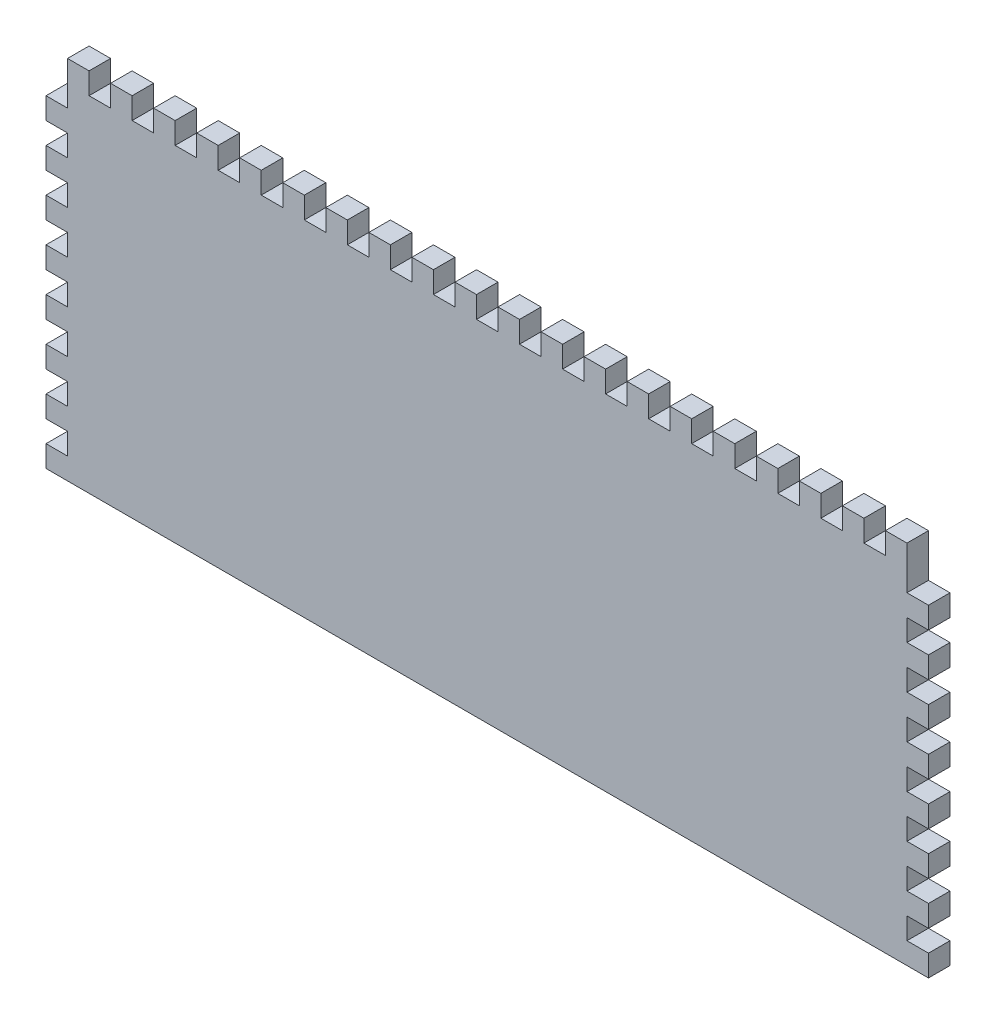
from build123d import *

# Parameters (mm, degrees)
SKETCH1_W               = 260.35
SKETCH1_H               = 107.95
BOSS_EXTRUDE1_DEPTH     = 6.35
SKETCH3_W               = 6.35
SKETCH3_H               = 6.35
CUT_EXTRUDE1_DEPTH      = 7.35
LPATTERN1_COUNT         = 8
LPATTERN1_PITCH         = 12.7
MIRROR1_COPY_1_SKETCH_W = 6.35
MIRROR1_COPY_1_SKETCH_H = 6.35
MIRROR1_COPY_1_DEPTH    = 7.35
MIRROR1_COPY_2_SKETCH_W = 6.35
MIRROR1_COPY_2_SKETCH_H = 6.35
MIRROR1_COPY_2_DEPTH    = 7.35
MIRROR1_COPY_3_SKETCH_W = 6.35
MIRROR1_COPY_3_SKETCH_H = 6.35
MIRROR1_COPY_3_DEPTH    = 7.35
MIRROR1_COPY_4_SKETCH_W = 6.35
MIRROR1_COPY_4_SKETCH_H = 6.35
MIRROR1_COPY_4_DEPTH    = 7.35
MIRROR1_COPY_5_SKETCH_W = 6.35
MIRROR1_COPY_5_SKETCH_H = 6.35
MIRROR1_COPY_5_DEPTH    = 7.35
MIRROR1_COPY_6_SKETCH_W = 6.35
MIRROR1_COPY_6_SKETCH_H = 6.35
MIRROR1_COPY_6_DEPTH    = 7.35
MIRROR1_COPY_7_SKETCH_W = 6.35
MIRROR1_COPY_7_SKETCH_H = 6.35
MIRROR1_COPY_7_DEPTH    = 7.35
SKETCH4_W               = 6.35
SKETCH4_H               = 6.35
CUT_EXTRUDE2_DEPTH      = 6.35
LPATTERN2_COUNT         = 21
LPATTERN2_PITCH         = 12.7


with BuildPart() as part:
    # Sketch1 → Boss-Extrude1 (new body)
    with BuildSketch(Plane.XY):
        Rectangle(SKETCH1_W, SKETCH1_H)
    extrude(amount=BOSS_EXTRUDE1_DEPTH)

    # Sketch3 → Cut-Extrude1 (cut, through all)
    with BuildSketch(Plane.XY.offset(6.35)):
        with Locations((127, -44.45)):
            Rectangle(SKETCH3_W, SKETCH3_H)
    cut_extrude1 = extrude(amount=-CUT_EXTRUDE1_DEPTH, mode=Mode.SUBTRACT)

    # LPattern1: Cut-Extrude1 ×8
    with Locations(*[(0, i * LPATTERN1_PITCH, 0) for i in range(1, LPATTERN1_COUNT)]):
        add(cut_extrude1, mode=Mode.SUBTRACT)

    # Mirror1: Cut-Extrude1 across plane
    add(cut_extrude1.mirror(Plane(origin=(0, 0, 0), x_dir=(0, 0, 1), z_dir=(1, 0, 0))), mode=Mode.SUBTRACT)

    # Mirror1 copy 1 sketch → Mirror1 copy 1 (cut, through all)
    with BuildSketch(Plane(origin=(0, 12.7, 6.35), x_dir=(-1, 0, 0), z_dir=(0, 0, 1))):
        with Locations((127, 44.45)):
            Rectangle(MIRROR1_COPY_1_SKETCH_W, MIRROR1_COPY_1_SKETCH_H)
    extrude(amount=-MIRROR1_COPY_1_DEPTH, mode=Mode.SUBTRACT)

    # Mirror1 copy 2 sketch → Mirror1 copy 2 (cut, through all)
    with BuildSketch(Plane(origin=(0, 25.4, 6.35), x_dir=(-1, 0, 0), z_dir=(0, 0, 1))):
        with Locations((127, 44.45)):
            Rectangle(MIRROR1_COPY_2_SKETCH_W, MIRROR1_COPY_2_SKETCH_H)
    extrude(amount=-MIRROR1_COPY_2_DEPTH, mode=Mode.SUBTRACT)

    # Mirror1 copy 3 sketch → Mirror1 copy 3 (cut, through all)
    with BuildSketch(Plane(origin=(0, 38.1, 6.35), x_dir=(-1, 0, 0), z_dir=(0, 0, 1))):
        with Locations((127, 44.45)):
            Rectangle(MIRROR1_COPY_3_SKETCH_W, MIRROR1_COPY_3_SKETCH_H)
    extrude(amount=-MIRROR1_COPY_3_DEPTH, mode=Mode.SUBTRACT)

    # Mirror1 copy 4 sketch → Mirror1 copy 4 (cut, through all)
    with BuildSketch(Plane(origin=(0, 50.8, 6.35), x_dir=(-1, 0, 0), z_dir=(0, 0, 1))):
        with Locations((127, 44.45)):
            Rectangle(MIRROR1_COPY_4_SKETCH_W, MIRROR1_COPY_4_SKETCH_H)
    extrude(amount=-MIRROR1_COPY_4_DEPTH, mode=Mode.SUBTRACT)

    # Mirror1 copy 5 sketch → Mirror1 copy 5 (cut, through all)
    with BuildSketch(Plane(origin=(0, 63.5, 6.35), x_dir=(-1, 0, 0), z_dir=(0, 0, 1))):
        with Locations((127, 44.45)):
            Rectangle(MIRROR1_COPY_5_SKETCH_W, MIRROR1_COPY_5_SKETCH_H)
    extrude(amount=-MIRROR1_COPY_5_DEPTH, mode=Mode.SUBTRACT)

    # Mirror1 copy 6 sketch → Mirror1 copy 6 (cut, through all)
    with BuildSketch(Plane(origin=(0, 76.2, 6.35), x_dir=(-1, 0, 0), z_dir=(0, 0, 1))):
        with Locations((127, 44.45)):
            Rectangle(MIRROR1_COPY_6_SKETCH_W, MIRROR1_COPY_6_SKETCH_H)
    extrude(amount=-MIRROR1_COPY_6_DEPTH, mode=Mode.SUBTRACT)

    # Mirror1 copy 7 sketch → Mirror1 copy 7 (cut, through all)
    with BuildSketch(Plane(origin=(0, 88.9, 6.35), x_dir=(-1, 0, 0), z_dir=(0, 0, 1))):
        with Locations((127, 44.45)):
            Rectangle(MIRROR1_COPY_7_SKETCH_W, MIRROR1_COPY_7_SKETCH_H)
    extrude(amount=-MIRROR1_COPY_7_DEPTH, mode=Mode.SUBTRACT)

    # Sketch4 → Cut-Extrude2 (cut)
    with BuildSketch(Plane.XY.offset(6.35)):
        with Locations((-127, 50.8)):
            Rectangle(SKETCH4_W, SKETCH4_H)
    cut_extrude2 = extrude(amount=-CUT_EXTRUDE2_DEPTH, mode=Mode.SUBTRACT)

    # LPattern2: Cut-Extrude2 ×21
    with Locations(*[(i * LPATTERN2_PITCH, 0, 0) for i in range(1, LPATTERN2_COUNT)]):
        add(cut_extrude2, mode=Mode.SUBTRACT)


solid = part.part
